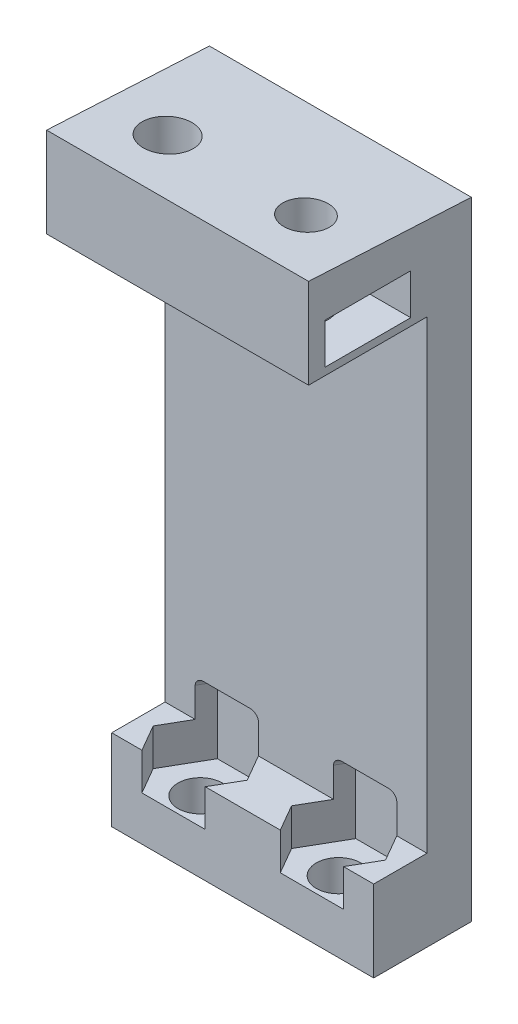
from build123d import *

# Parameters (mm, degrees)
BOSS_EXTRUDE1_START = -0.4
BOSS_EXTRUDE1_DEPTH = 17.7
CUT_EXTRUDE1_REACH  = 5
SKETCH3_R           = 1.5
BOSS_EXTRUDE2_DEPTH = 2.5
SKETCH3_3_R         = 1.5
CUT_EXTRUDE2_DEPTH  = 5
FILLET2_R           = 0.5
SKETCH4_R           = 1.5
SKETCH4_R_2         = 1.65
CUT_EXTRUDE3_DEPTH  = 7.077263094
CUT_EXTRUDE4_START  = -0.5
SKETCH5_R           = 1.65
SKETCH5_R_2         = 1.5
CUT_EXTRUDE4_DEPTH  = 2.75


with BuildPart() as part:
    # Sketch2 → Boss-Extrude1 (new body)
    with BuildSketch(Plane.ZY.offset(104.655623537).offset(BOSS_EXTRUDE1_START)):
        Polygon((3.654210553, -50.917330539), (-2.945789447, -50.917330539), (-2.945789447, -8.529639022), (8.054210553, -7.952375928), (8.054210553, -14.029639022), (0.054210553, -14.029639022), (0.054210553, -47.917330539), (3.654210553, -47.917330539), align=None)
    extrude(amount=-BOSS_EXTRUDE1_DEPTH)

    # Sketch3 → Cut-Extrude1 (cut, up to next)
    with BuildSketch(Plane(origin=(0, -47.917330539, 0), x_dir=(1, 0, 0), z_dir=(0, 1, 0)), mode=Mode.PRIVATE) as cut_extrude1_sk1:
        with Locations((-90.731050017, -1.854210553)):
            Circle(SKETCH3_R)
    cut_extrude1_tool1 = extrude(cut_extrude1_sk1.sketch, amount=-CUT_EXTRUDE1_REACH, mode=Mode.PRIVATE) & part.part
    add(cut_extrude1_tool1.solids().sort_by_distance((-90.73105, -47.917331, 1.854211))[0], mode=Mode.SUBTRACT)
    # Sketch3 → Cut-Extrude1 (cut, up to next)
    with BuildSketch(Plane(origin=(0, -47.917330539, 0), x_dir=(1, 0, 0), z_dir=(0, 1, 0)), mode=Mode.PRIVATE) as cut_extrude1_sk2:
        with Locations((-100.080197056, -1.854210553)):
            Circle(SKETCH3_R)
    cut_extrude1_tool2 = extrude(cut_extrude1_sk2.sketch, amount=-CUT_EXTRUDE1_REACH, mode=Mode.PRIVATE) & part.part
    add(cut_extrude1_tool2.solids().sort_by_distance((-100.080197, -47.917331, 1.854211))[0], mode=Mode.SUBTRACT)

    # Sketch3_4 → Boss-Extrude2 (add)
    with BuildSketch(Plane(origin=(0, -47.917330539, 0), x_dir=(1, 0, 0), z_dir=(0, 1, 0))):
        Polygon((-102.216393052, -3.654210553), (-103.255623537, -1.854210553), (-102.216393052, -0.054210553), (-104.255623537, -0.054210553), (-104.255623537, -3.654210553), align=None)
        Polygon((-96.904770576, -1.854210553), (-97.94400106, -3.654210553), (-92.867246013, -3.654210553), (-93.906476498, -1.854210553), (-92.867246013, -0.054210553), (-97.94400106, -0.054210553), align=None)
        Polygon((-87.555623537, -1.854210553), (-88.594854021, -3.654210553), (-86.555623537, -3.654210553), (-86.555623537, -0.054210553), (-88.594854021, -0.054210553), align=None)
    extrude(amount=BOSS_EXTRUDE2_DEPTH)

    # Sketch3_3 → Cut-Extrude2 (cut)
    with BuildSketch(Plane(origin=(0, -47.917330539, 0), x_dir=(1, 0, 0), z_dir=(0, 1, 0))):
        Polygon((-103.255623537, -1.854210553), (-101.667910296, -4.604210553), (-98.492483816, -4.604210553), (-96.904770576, -1.854210553), (-98.492483816, 0.895789447), (-101.667910296, 0.895789447), align=None)
        with Locations((-100.080197056, -1.854210553)):
            Circle(SKETCH3_3_R, mode=Mode.SUBTRACT)
        Polygon((-87.555623537, -1.854210553), (-89.143336777, 0.895789447), (-92.318763257, 0.895789447), (-93.906476498, -1.854210553), (-92.318763257, -4.604210553), (-89.143336777, -4.604210553), align=None)
        with Locations((-90.731050017, -1.854210553)):
            Circle(SKETCH3_3_R, mode=Mode.SUBTRACT)
    extrude(amount=CUT_EXTRUDE2_DEPTH, mode=Mode.SUBTRACT)

    # Fillet2
    fillet2_edges = [part.edges().sort_by_distance(p)[0] for p in [
        (-98.218242438, -42.917330539, -0.420789447),
        (-100.080197056, -42.917330539, -0.895789447),
        (-101.942151674, -42.917330539, -0.420789447),
        (-88.869095399, -42.917330539, -0.420789447),
        (-90.731050017, -42.917330539, -0.895789447),
        (-92.593004635, -42.917330539, -0.420789447),
    ]]
    fillet(fillet2_edges, radius=FILLET2_R)

    # Sketch4 → Cut-Extrude3 (cut, through all)
    with BuildSketch(Plane.XZ.offset(14.029639022)):
        with Locations((-90.731050017, 4.054210553)):
            Circle(SKETCH4_R)
        with Locations((-100.080197056, 4.054210553)):
            Circle(SKETCH4_R_2)
    extrude(amount=-CUT_EXTRUDE3_DEPTH, mode=Mode.SUBTRACT)

    # Sketch5 → Cut-Extrude4 (cut)
    with BuildSketch(Plane.XZ.offset(14.029639022).offset(CUT_EXTRUDE4_START)):
        Polygon((-103.128828617, 4.054210553), (-101.454512837, 6.954210553), (-104.255623537, 6.954210553), (-104.255623537, 1.154210553), (-101.454512837, 1.154210553), align=None)
        Polygon((-101.454512837, 1.154210553), (-98.105881275, 1.154210553), (-96.431565495, 4.054210553), (-98.105881275, 6.954210553), (-101.454512837, 6.954210553), (-103.128828617, 4.054210553), align=None)
        with Locations((-100.080197056, 4.054210553)):
            Circle(SKETCH5_R, mode=Mode.SUBTRACT)
        Polygon((-92.705365798, 1.154210553), (-89.356734237, 1.154210553), (-87.682418456, 4.054210553), (-89.356734237, 6.954210553), (-92.705365798, 6.954210553), (-94.379681578, 4.054210553), align=None)
        with Locations((-90.731050017, 4.054210553)):
            Circle(SKETCH5_R_2, mode=Mode.SUBTRACT)
        Polygon((-89.356734237, 6.954210553), (-87.682418456, 4.054210553), (-89.356734237, 1.154210553), (-86.555623537, 1.154210553), (-86.555623537, 6.954210553), align=None)
    extrude(amount=-CUT_EXTRUDE4_DEPTH, mode=Mode.SUBTRACT)


solid = part.part
